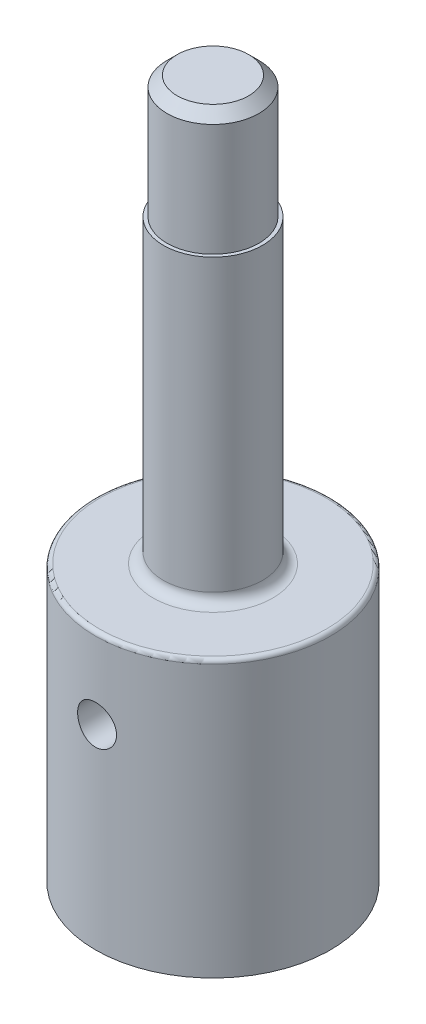
from build123d import *

# Parameters (mm, degrees)
REDONDEO1_R           = 5
REDONDEO2_R           = 2
CROQUIS2_R            = 9.525
CORTAR_EXTRUIR1_DEPTH = 60
REDONDEO3_R           = 2
CHAFL_N1_SIZE         = 5


with BuildPart() as part:
    # Croquis1 → Revolución2 (revolve)
    with BuildSketch(Plane.XY):
        Polygon((0, 175.625), (22.5, 175.625), (22.5, 115.625), (24.25, 115.625), (24.25, -31.375), (57.5, -31.375), (57.5, -166.375), (35.25, -166.375), (35.25, -46.375), (0, -46.375), align=None)
    revolve(axis=Axis((0, 96.1875, 0), (0, -1, 0)))

    # Redondeo1
    redondeo1_edges = [part.edges().sort_by_distance(p)[0] for p in [
        (-24.25, -31.375, 0),
    ]]
    fillet(redondeo1_edges, radius=REDONDEO1_R)

    # Redondeo2
    redondeo2_edges = [part.edges().sort_by_distance(p)[0] for p in [
        (-35.25, -46.375, 0),
    ]]
    fillet(redondeo2_edges, radius=REDONDEO2_R)

    # Croquis2 → Cortar-Extruir1 (cut, symmetric)
    with BuildSketch(Plane.XY):
        with Locations((0, -70.9)):
            Circle(CROQUIS2_R)
    extrude(amount=CORTAR_EXTRUIR1_DEPTH, both=True, mode=Mode.SUBTRACT)

    # Redondeo3
    redondeo3_edges = [part.edges().sort_by_distance(p)[0] for p in [
        (-57.5, -31.375, 0),
    ]]
    fillet(redondeo3_edges, radius=REDONDEO3_R)

    # Chaflán1
    chafl_n1_edges = [part.edges().sort_by_distance(p)[0] for p in [
        (-22.5, 175.625, 0),
    ]]
    chamfer(chafl_n1_edges, length=CHAFL_N1_SIZE)


solid = part.part
